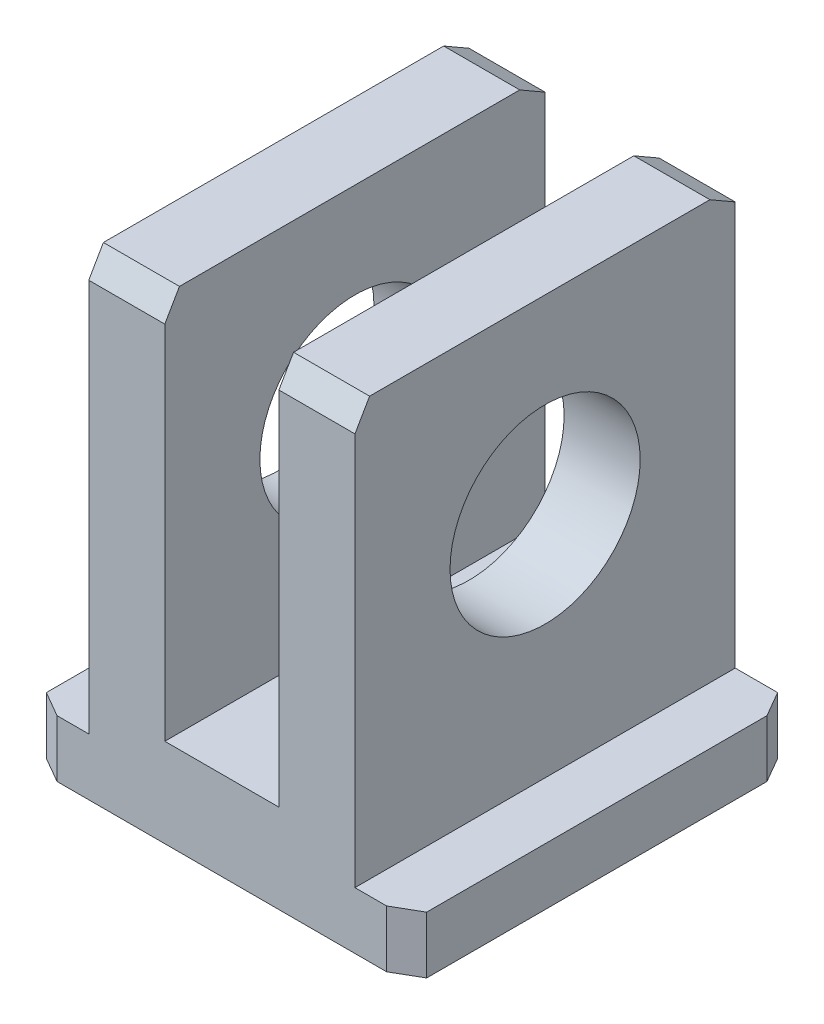
from build123d import *

# Parameters (mm, degrees)
SKETCH1_W             = 4.5
SKETCH1_H             = 30
BOSS_EXTRUDE1_DEPTH   = 4.5
SKETCH1_3_W           = 6
SKETCH1_3_H           = 30
BOSS_EXTRUDE2_DEPTH   = 37.5
SKETCH1_4_W           = 4.5
SKETCH1_4_H           = 30
BOSS_EXTRUDE3_DEPTH   = 7
CUT_EXTRUDE1_REACH    = 12.5
SKETCH2_R             = 7.5
CHAMFER1_SIZE         = 2
CHAMFER1_SIZE2        = 1.154700538
CHAMFER1_PART_2_SIZE  = 2
CHAMFER1_PART_2_SIZE2 = 1.154700538
CHAMFER1_PART_3_SIZE  = 2
CHAMFER1_PART_3_SIZE2 = 1.154700538


with BuildPart() as part:
    # Sketch1 → Boss-Extrude1 (new body)
    with BuildSketch(Plane(origin=(0, 0, 0), x_dir=(1, 0, 0), z_dir=(0, 1, 0))):
        with Locations((12.75, 15)):
            Rectangle(SKETCH1_W, SKETCH1_H)
    extrude(amount=BOSS_EXTRUDE1_DEPTH)

    # Sketch1_3 → Boss-Extrude2 (add)
    with BuildSketch(Plane(origin=(0, 0, 0), x_dir=(1, 0, 0), z_dir=(0, 1, 0))):
        with Locations((7.5, 15)):
            Rectangle(SKETCH1_3_W, SKETCH1_3_H)
    extrude(amount=BOSS_EXTRUDE2_DEPTH)

    # Sketch1_4 → Boss-Extrude3 (add)
    with BuildSketch(Plane(origin=(0, 0, 0), x_dir=(1, 0, 0), z_dir=(0, 1, 0))):
        with Locations((2.25, 15)):
            Rectangle(SKETCH1_4_W, SKETCH1_4_H)
    extrude(amount=BOSS_EXTRUDE3_DEPTH)

    # Sketch2 → Cut-Extrude1 (cut, up to next)
    with BuildSketch(Plane(origin=(10.5, 0, 0), x_dir=(0, 0, -1), z_dir=(1, 0, 0)), mode=Mode.PRIVATE) as cut_extrude1_sk1:
        with Locations((15, 22.5)):
            Circle(SKETCH2_R)
    cut_extrude1_tool1 = extrude(cut_extrude1_sk1.sketch, amount=-CUT_EXTRUDE1_REACH, mode=Mode.PRIVATE) & part.part
    add(cut_extrude1_tool1.solids().sort_by_distance((10.5, 22.5, -15))[0], mode=Mode.SUBTRACT)

    # Chamfer1
    chamfer1_edges = [part.edges().sort_by_distance(p)[0] for p in [
        (7.5, 37.5, -30),
    ]]
    chamfer1_side = [part.faces().sort_by_distance(p)[0] for p in [
        (7.5, 37.5, -15),
    ]]
    chamfer(chamfer1_edges, length=CHAMFER1_SIZE, length2=CHAMFER1_SIZE2, reference=chamfer1_side[0])

    # Chamfer1 part 2
    chamfer1_part_2_edges = [part.edges().sort_by_distance(p)[0] for p in [
        (7.5, 37.5, 0),
        (15, 2.25, 0),
    ]]
    chamfer1_part_2_side = [part.faces().sort_by_distance(p)[0] for p in [
        (7.286585366, 15.806910569, 0),
    ]]
    chamfer(chamfer1_part_2_edges, length=CHAMFER1_PART_2_SIZE, length2=CHAMFER1_PART_2_SIZE2, reference=chamfer1_part_2_side[0])

    # Chamfer1 part 3
    chamfer1_part_3_edges = [part.edges().sort_by_distance(p)[0] for p in [
        (15, 2.25, -30),
    ]]
    chamfer1_part_3_side = [part.faces().sort_by_distance(p)[0] for p in [
        (15, 2.25, -15),
    ]]
    chamfer(chamfer1_part_3_edges, length=CHAMFER1_PART_3_SIZE, length2=CHAMFER1_PART_3_SIZE2, reference=chamfer1_part_3_side[0])

    # Mirror1: part across plane


with BuildPart() as part_1:
    add(part.part)
    add(part.part.mirror(Plane(origin=(0, 7, 0), x_dir=(0, 0, 1), z_dir=(-1, 0, 0))))


solid = part_1.part
